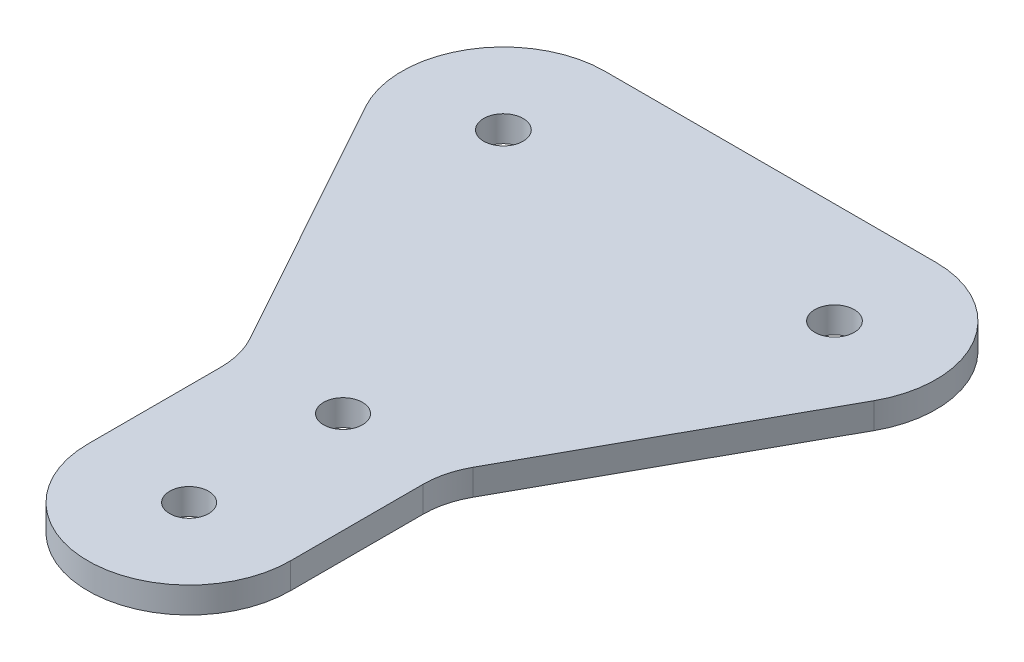
from build123d import *

# Parameters (mm, degrees)
SKETCH1_R           = 2.38125
SKETCH1_R_2         = 12.413
SKETCH1_R_3         = 2.413
BOSS_EXTRUDE1_DEPTH = 3.175
FILLET1_R           = 10


with BuildPart() as part:
    # Sketch1 → Boss-Extrude1 (new body)
    with BuildSketch(Plane(origin=(0, 0, 0), x_dir=(1, 0, 0), z_dir=(0, 1, 0))):
        with BuildLine():
            ThreePointArc((-8.046041628, -19.942425209), (-11.245341357, -24.172368354), (-12.38125, -29.352875022))
            ThreePointArc((-12.38125, -29.352875022), (0, -41.734125022), (12.38125, -29.352875022))
            ThreePointArc((12.38125, -29.352875022), (11.245341357, -24.172368354), (8.046041628, -19.942425209))
            add(Edge.make_bspline(
                [(-8.046041628, -19.942425209), (-7.058484548, -20.785974262), (-4.539606647, -22.332996604), (0, -23.235965205), (4.539606647, -22.332996604), (7.058484548, -20.785974262), (8.046041628, -19.942425209)],
                knots=[4.00497242, 4.00497242, 4.00497242, 4.00497242, 4.319689899, 4.71238898, 5.105088062, 5.419805541, 5.419805541, 5.419805541, 5.419805541], degree=3))
        make_face()
        with Locations((0, -29.352875022)):
            Circle(SKETCH1_R, mode=Mode.SUBTRACT)
        with BuildLine():
            Line((-12.38125, -10.532423695), (-12.38125, -29.352875022))
            ThreePointArc((-12.38125, -29.352875022), (-11.245341357, -24.172368354), (-8.046041628, -19.942425209))
            add(Edge.make_bspline(
                [(-12.38125, -10.532423695), (-12.38125, -10.937602676), (-12.301779915, -12.5583186), (-11.507079063, -15.737360854), (-9.718393414, -18.414272732), (-8.290741365, -19.733408195), (-8.046041628, -19.942425209)],
                knots=[3.141592654, 3.141592654, 3.141592654, 3.141592654, 3.239767424, 3.534291735, 3.926990817, 4.00497242, 4.00497242, 4.00497242, 4.00497242], degree=3))
        make_face()
        with BuildLine():
            ThreePointArc((8.046041628, -19.942425209), (0, -16.971625022), (-8.046041628, -19.942425209))
            add(Edge.make_bspline(
                [(-8.046041628, -19.942425209), (-7.058484548, -20.785974262), (-4.539606647, -22.332996604), (0, -23.235965205), (4.539606647, -22.332996604), (7.058484548, -20.785974262), (8.046041628, -19.942425209)],
                knots=[4.00497242, 4.00497242, 4.00497242, 4.00497242, 4.319689899, 4.71238898, 5.105088062, 5.419805541, 5.419805541, 5.419805541, 5.419805541], degree=3))
        make_face()
        with BuildLine():
            ThreePointArc((8.046041628, -19.942425209), (11.245341357, -24.172368354), (12.38125, -29.352875022))
            Line((12.38125, -29.352875022), (12.38125, -10.532423695))
            add(Edge.make_bspline(
                [(8.046041628, -19.942425209), (8.290741365, -19.733408195), (9.718393414, -18.414272732), (11.736565023, -15.393916665), (12.38125, -12.152921351), (12.38125, -10.532423695)],
                knots=[5.419805541, 5.419805541, 5.419805541, 5.419805541, 5.497787144, 5.890486225, 6.283185307, 6.283185307, 6.283185307, 6.283185307], degree=3))
        make_face()
        with BuildLine():
            add(Edge.make_bspline(
                [(12.38125, -10.532423695), (12.38125, -8.911926038), (11.736565023, -5.670930724), (8.982733505, -1.549600459), (4.861396275, 1.204142363), (0, 2.171117815), (-4.861396275, 1.204142363), (-8.982733505, -1.549600459), (-11.507079063, -5.327486536), (-12.301779915, -8.506528789), (-12.38125, -10.127244714), (-12.38125, -10.532423695)],
                knots=[0, 0, 0, 0, 0.392699082, 0.785398163, 1.178097245, 1.570796327, 1.963495408, 2.35619449, 2.748893572, 3.043417883, 3.141592654, 3.141592654, 3.141592654, 3.141592654], degree=3))
            add(Edge.make_bspline(
                [(-12.38125, -10.532423695), (-12.38125, -10.937602676), (-12.301779915, -12.5583186), (-11.507079063, -15.737360854), (-9.718393414, -18.414272732), (-8.290741365, -19.733408195), (-8.046041628, -19.942425209)],
                knots=[3.141592654, 3.141592654, 3.141592654, 3.141592654, 3.239767424, 3.534291735, 3.926990817, 4.00497242, 4.00497242, 4.00497242, 4.00497242], degree=3))
            ThreePointArc((-8.046041628, -19.942425209), (0, -16.971625022), (8.046041628, -19.942425209))
            add(Edge.make_bspline(
                [(8.046041628, -19.942425209), (8.290741365, -19.733408195), (9.718393414, -18.414272732), (11.736565023, -15.393916665), (12.38125, -12.152921351), (12.38125, -10.532423695)],
                knots=[5.419805541, 5.419805541, 5.419805541, 5.419805541, 5.497787144, 5.890486225, 6.283185307, 6.283185307, 6.283185307, 6.283185307], degree=3))
        make_face()
        with BuildLine():
            add(Edge.make_bspline(
                [(2.38125, -10.532423695), (2.38125, -6.408035977), (-1.190625, -8.470229836), (-4.7625, -10.532423695), (-1.190625, -12.594617554), (2.38125, -14.656811413), (2.38125, -10.532423695)],
                knots=[0, 0, 0, 2.094395102, 2.094395102, 4.188790205, 4.188790205, 6.283185307, 6.283185307, 6.283185307], degree=2, weights=[1, 0.5, 1, 0.5, 1, 0.5, 1]))
        make_face(mode=Mode.SUBTRACT)
        with BuildLine():
            Line((-31.105374648, 23.312068051), (-12.38125, -10.532423695))
            add(Edge.make_bspline(
                [(12.38125, -10.532423695), (12.38125, -8.911926038), (11.736565023, -5.670930724), (8.982733505, -1.549600459), (4.861396275, 1.204142363), (0, 2.171117815), (-4.861396275, 1.204142363), (-8.982733505, -1.549600459), (-11.507079063, -5.327486536), (-12.301779915, -8.506528789), (-12.38125, -10.127244714), (-12.38125, -10.532423695)],
                knots=[0, 0, 0, 0, 0.392699082, 0.785398163, 1.178097245, 1.570796327, 1.963495408, 2.35619449, 2.748893572, 3.043417883, 3.141592654, 3.141592654, 3.141592654, 3.141592654], degree=3))
            Line((12.38125, -10.532423695), (31.105374628, 23.312068057))
            ThreePointArc((31.105374628, 23.312068057), (9.550975447, 23.016676344), (20.2438, 41.734124978))
            Line((20.2438, 41.734124978), (-20.2438, 41.734124978))
            ThreePointArc((-20.2438, 41.734124978), (-11.466483525, 38.098441453), (-7.8308, 29.321124978))
            ThreePointArc((-7.8308, 29.321124978), (-17.140749655, 17.302237861), (-31.105374648, 23.312068051))
        make_face()
        with Locations((20.243799976, 29.321124978)):
            Circle(SKETCH1_R_2)
        with Locations((20.2438, 29.321125022)):
            Circle(SKETCH1_R_3, mode=Mode.SUBTRACT)
        with Locations((-20.2438, 29.321124978)):
            Circle(SKETCH1_R_2)
        with Locations((-20.2438, 29.321124978)):
            Circle(SKETCH1_R_3, mode=Mode.SUBTRACT)
    extrude(amount=BOSS_EXTRUDE1_DEPTH)

    # Fillet1
    fillet1_edges = [part.edges().sort_by_distance(p)[0] for p in [
        (-12.38125, 1.5875, 10.532423695),
        (12.38125, 1.5875, 10.532423695),
    ]]
    fillet(fillet1_edges, radius=FILLET1_R)


solid = part.part
